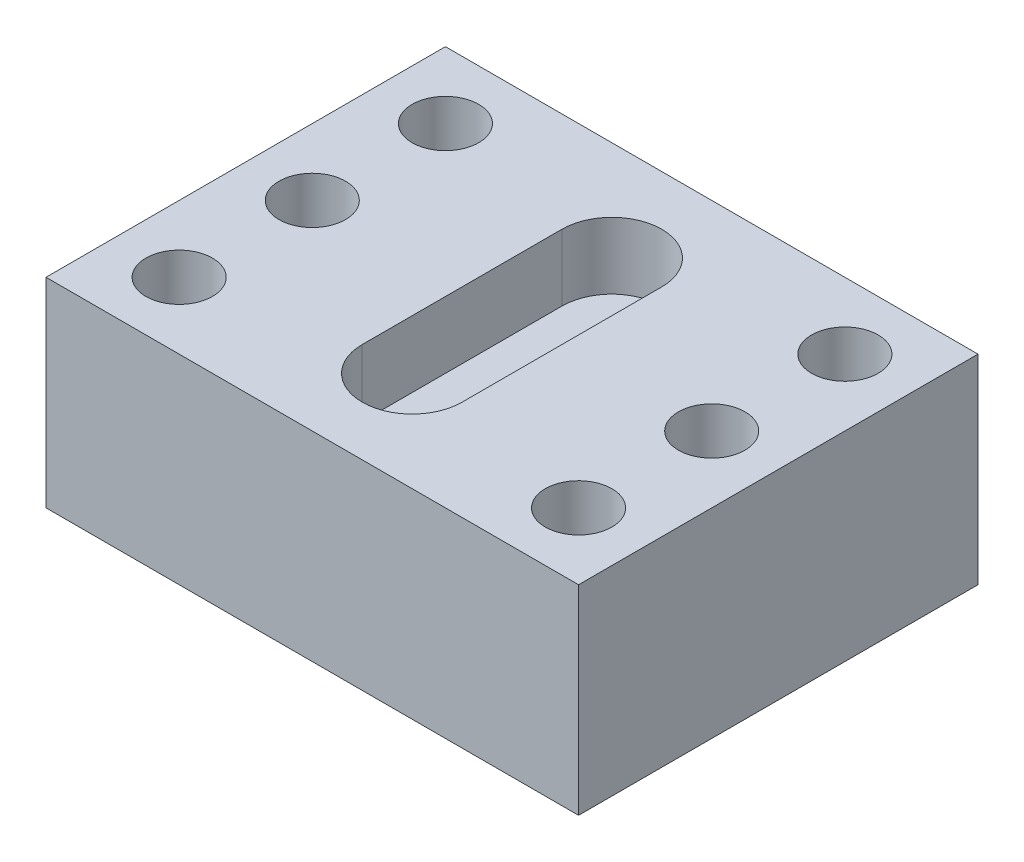
from build123d import *

# Parameters (mm, degrees)
SKETCH1_W           = 203.2
SKETCH1_H           = 152.4
BOSS_EXTRUDE1_DEPTH = 76.2
SKETCH2_R           = 12.7
CUT_EXTRUDE1_DEPTH  = 25.4


with BuildPart() as part:
    # Sketch1 → Boss-Extrude1 (new body)
    with BuildSketch(Plane(origin=(0, 0, 0), x_dir=(1, 0, 0), z_dir=(0, 1, 0))):
        Rectangle(SKETCH1_W, SKETCH1_H)
    extrude(amount=BOSS_EXTRUDE1_DEPTH)

    # Sketch2 → Cut-Extrude1 (cut)
    with BuildSketch(Plane(origin=(0, 76.2, 0), x_dir=(1, 0, 0), z_dir=(0, 1, 0))):
        with Locations((-76.2, -50.8)):
            Circle(SKETCH2_R)
        with Locations((-76.2, 0)):
            Circle(SKETCH2_R)
        with Locations((-76.2, 50.8)):
            Circle(SKETCH2_R)
        with Locations((76.2, 50.8)):
            Circle(SKETCH2_R)
        with Locations((76.2, -50.8)):
            Circle(SKETCH2_R)
        with Locations((76.2, 0)):
            Circle(SKETCH2_R)
        with BuildLine():
            Line((-19.05, -38.1), (-19.05, 38.1))
            ThreePointArc((-19.05, 38.1), (0, 57.15), (19.05, 38.1))
            Line((19.05, 38.1), (19.05, -38.1))
            ThreePointArc((19.05, -38.1), (0, -57.15), (-19.05, -38.1))
        make_face()
    extrude(amount=-CUT_EXTRUDE1_DEPTH, mode=Mode.SUBTRACT)


solid = part.part
